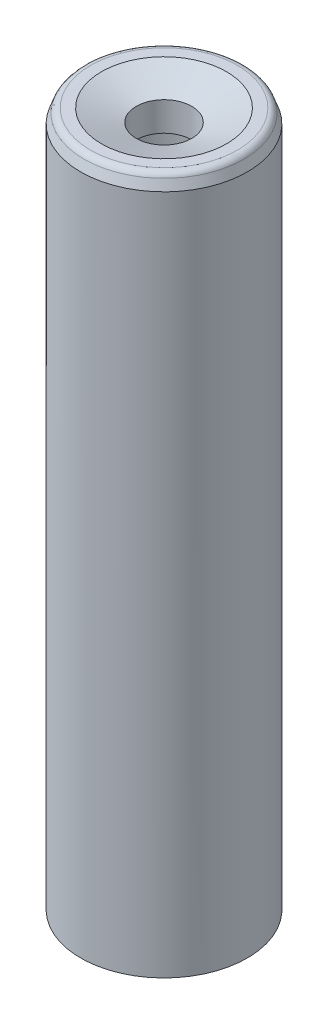
from build123d import *

# Parameters (mm, degrees)
CROQUIS1_R              = 6
CROQUIS1_R_2            = 4
SALIENTE_EXTRUIR1_DEPTH = 40
CROQUIS2_R              = 4
SALIENTE_EXTRUIR2_DEPTH = 3
CROQUIS3_R              = 2
CORTAR_EXTRUIR1_DEPTH   = 40
CHAFL_N1_SIZE           = 2.5
CHAFL_N1_SIZE2          = 0.909925586
CHAFL_N2_SIZE           = 1
CHAFL_N2_SIZE2          = 0.363970234
REDONDEO1_R             = 0.5
CROQUIS4_R              = 6
CROQUIS4_R_2            = 4
SALIENTE_EXTRUIR3_DEPTH = 10


with BuildPart() as part:
    # Croquis1 → Saliente-Extruir1 (new body)
    with BuildSketch(Plane(origin=(0, 0, 0), x_dir=(1, 0, 0), z_dir=(0, 1, 0))):
        Circle(CROQUIS1_R)
        Circle(CROQUIS1_R_2, mode=Mode.SUBTRACT)
    extrude(amount=SALIENTE_EXTRUIR1_DEPTH)

    # Croquis2 → Saliente-Extruir2 (add)
    with BuildSketch(Plane(origin=(0, 37, 0), x_dir=(1, 0, 0), z_dir=(0, 1, 0))):
        Circle(CROQUIS2_R)
    extrude(amount=SALIENTE_EXTRUIR2_DEPTH)

    # Croquis3 → Cortar-Extruir1 (cut)
    with BuildSketch(Plane(origin=(0, 40, 0), x_dir=(1, 0, 0), z_dir=(0, 1, 0))):
        Circle(CROQUIS3_R)
    extrude(amount=-CORTAR_EXTRUIR1_DEPTH, mode=Mode.SUBTRACT)

    # Chaflán1
    chafl_n1_edges = [part.edges().sort_by_distance(p)[0] for p in [
        (-2, 40, 0),
    ]]
    chafl_n1_side = [part.faces().sort_by_distance(p)[0] for p in [
        (-5.830294373, 40, 0),
    ]]
    chamfer(chafl_n1_edges, length=CHAFL_N1_SIZE, length2=CHAFL_N1_SIZE2, reference=chafl_n1_side[0])

    # Chaflán2
    chafl_n2_edges = [part.edges().sort_by_distance(p)[0] for p in [
        (-6, 40, 0),
    ]]
    chafl_n2_side = [part.faces().sort_by_distance(p)[0] for p in [
        (-6, 20, 0),
    ]]
    chamfer(chafl_n2_edges, length=CHAFL_N2_SIZE, length2=CHAFL_N2_SIZE2, reference=chafl_n2_side[0])

    # Redondeo1
    redondeo1_edges = [part.edges().sort_by_distance(p)[0] for p in [
        (-5.636029766, 40, 0),
    ]]
    fillet(redondeo1_edges, radius=REDONDEO1_R)

    # Croquis4 → Saliente-Extruir3 (add)
    with BuildSketch(Plane.XZ):
        Circle(CROQUIS4_R)
        Circle(CROQUIS4_R_2, mode=Mode.SUBTRACT)
    extrude(amount=SALIENTE_EXTRUIR3_DEPTH)


solid = part.part
